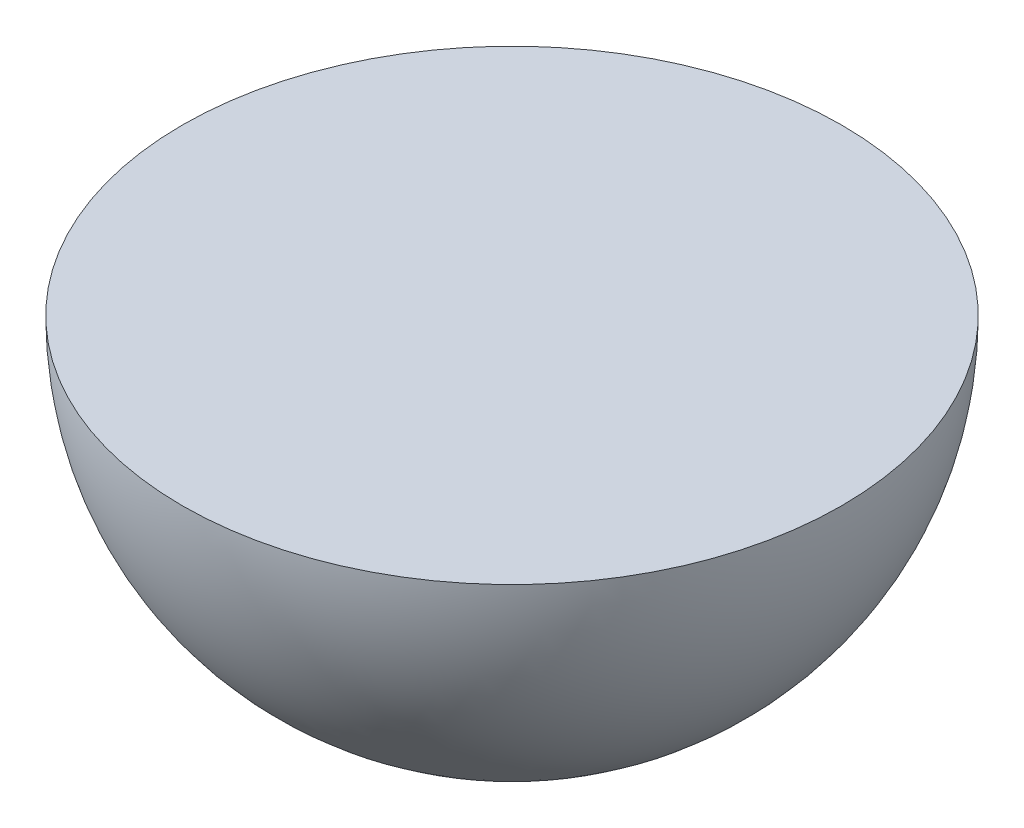
from build123d import *


with BuildPart() as part:
    # Sketch1 → Revolve1 (revolve)
    with BuildSketch(Plane.XY):
        with BuildLine():
            Line((-4.8, 0), (0, 0))
            Line((0, 0), (0, -4.8))
            ThreePointArc((0, -4.8), (-3.39411255, -3.39411255), (-4.8, 0))
        make_face()
    revolve(axis=Axis((0, 0, 0), (0, -1, 0)))


solid = part.part
